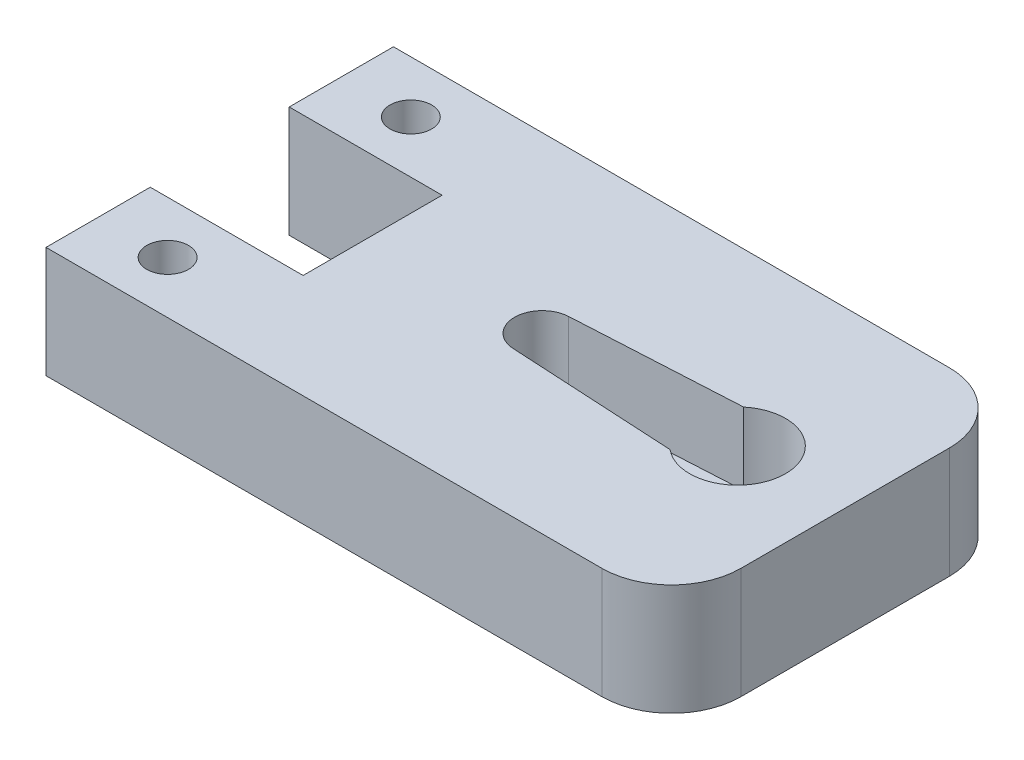
from build123d import *

# Parameters (mm, degrees)
BOSS_EXTRUDE1_DEPTH = 8
CUT_EXTRUDE1_DEPTH  = 5.2
SKETCH3_R           = 2.3
BOSS_EXTRUDE2_DEPTH = 1
SKETCH4_R           = 1.25
CUT_EXTRUDE2_DEPTH  = 4.8
SKETCH5_R           = 1.5
SKETCH5_W           = 11
SKETCH5_H           = 10
CUT_EXTRUDE3_DEPTH  = 9
SKETCH7_R           = 0.6
BOSS_EXTRUDE3_DEPTH = 1.2


with BuildPart() as part:
    # Sketch1 → Boss-Extrude1 (new body)
    with BuildSketch(Plane(origin=(0, 0, 0), x_dir=(1, 0, 0), z_dir=(0, 1, 0))):
        with BuildLine():
            Line((5, 0), (40, 0))
            ThreePointArc((40, 0), (43.535533906, 1.464466094), (45, 5))
            Line((45, 5), (45, 20))
            ThreePointArc((45, 20), (43.535533906, 23.535533906), (40, 25))
            Line((40, 25), (5, 25))
            Line((5, 25), (0, 25))
            Line((0, 25), (0, 20))
            Line((0, 20), (0, 5))
            Line((0, 5), (0, 0))
            Line((0, 0), (5, 0))
        make_face()
    extrude(amount=BOSS_EXTRUDE1_DEPTH)

    # Sketch2 → Cut-Extrude1 (cut)
    with BuildSketch(Plane(origin=(0, 8, 0), x_dir=(1, 0, 0), z_dir=(0, 1, 0))):
        with BuildLine():
            Line((35.050927797, 15.15), (23.100878033, 14.49702088))
            ThreePointArc((23.100878033, 14.49702088), (21.21, 12.5), (23.100878033, 10.50297912))
            Line((23.100878033, 10.50297912), (35.050927797, 9.85))
            ThreePointArc((35.050927797, 9.85), (40.71, 12.5), (35.050927797, 15.15))
        make_face()
    extrude(amount=-CUT_EXTRUDE1_DEPTH, mode=Mode.SUBTRACT)

    # Sketch3 → Boss-Extrude2 (add)
    with BuildSketch(Plane(origin=(0, 2.8, 0), x_dir=(1, 0, 0), z_dir=(0, 1, 0))):
        with Locations((37.26, 12.5)):
            Circle(SKETCH3_R)
    extrude(amount=BOSS_EXTRUDE2_DEPTH)

    # Sketch4 → Cut-Extrude2 (cut, through all)
    with BuildSketch(Plane(origin=(0, 3.8, 0), x_dir=(1, 0, 0), z_dir=(0, 1, 0))):
        with Locations((37.26, 12.5)):
            Circle(SKETCH4_R)
    extrude(amount=-CUT_EXTRUDE2_DEPTH, mode=Mode.SUBTRACT)

    # Sketch5 → Cut-Extrude3 (cut, through all)
    with BuildSketch(Plane(origin=(0, 8, 0), x_dir=(1, 0, 0), z_dir=(0, 1, 0))):
        with Locations((5, 21.25)):
            Circle(SKETCH5_R)
        with Locations((5, 3.75)):
            Circle(SKETCH5_R)
        with Locations((5.5, 12.5)):
            Rectangle(SKETCH5_W, SKETCH5_H)
    extrude(amount=-CUT_EXTRUDE3_DEPTH, mode=Mode.SUBTRACT)

    # Sketch7 → Boss-Extrude3 (add)
    with BuildSketch(Plane(origin=(0, 2.8, 0), x_dir=(1, 0, 0), z_dir=(0, 1, 0))):
        with Locations((22.81, 12.5)):
            Circle(SKETCH7_R)
    extrude(amount=BOSS_EXTRUDE3_DEPTH)


solid = part.part
